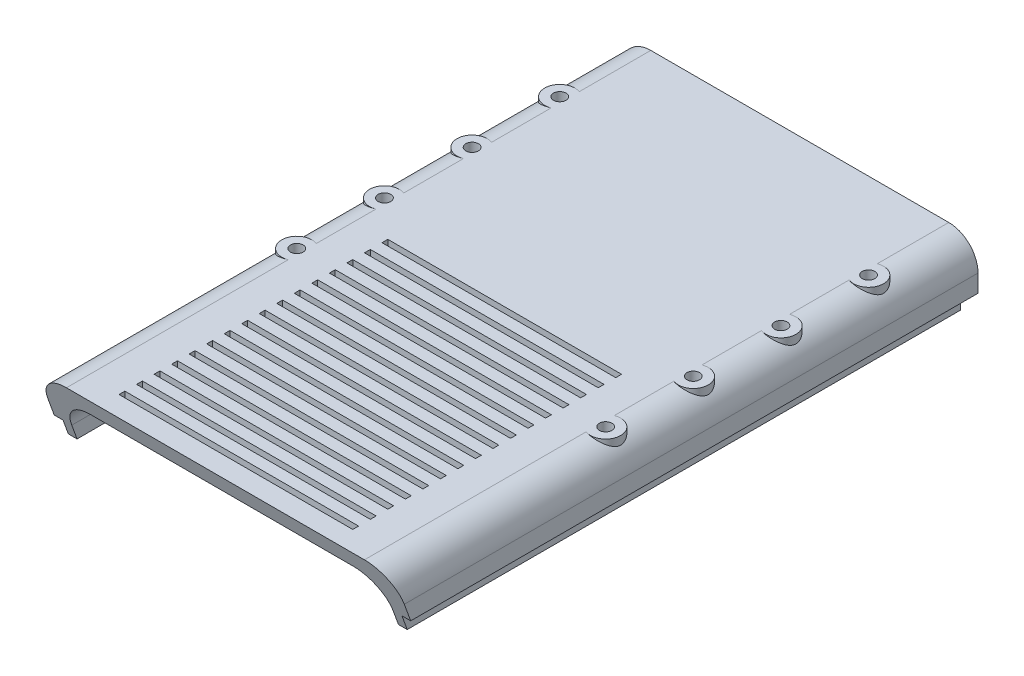
from build123d import *

# Parameters (mm, degrees)
SALIENTE_EXTRUIR1_DEPTH = 3
SALIENTE_EXTRUIR2_DEPTH = 200
CORTAR_EXTRUIR3_DEPTH   = 123
CORTAR_EXTRUIR5_REACH   = 23
CROQUIS6_W              = 80
CROQUIS6_H              = 2
CROQUIS7_W              = 3
CROQUIS7_H              = 3
CORTAR_EXTRUIR6_DEPTH   = 5
CROQUIS8_R              = 5.15
CROQUIS8_R_2            = 2.15
CROQUIS8_R_3            = 5.092623087
CROQUIS8_R_4            = 2.158198504
CROQUIS8_R_5            = 2.156580462
SALIENTE_EXTRUIR3_DEPTH = 21
CORTAR_EXTRUIR7_REACH   = 23
CROQUIS8_2_R            = 2.15
CROQUIS8_2_R_2          = 2.158198504
CROQUIS8_2_R_3          = 2.156580462


with BuildPart() as part:
    # Croquis1 → Saliente-Extruir1 (new body)
    with BuildSketch(Plane.XY):
        with BuildLine():
            Line((-45, 46), (45, 46))
            ThreePointArc((45, 46), (52.071067812, 43.071067812), (55, 36))
            Line((55, 36), (-55, 36))
            ThreePointArc((-55, 36), (-52.071067812, 43.071067812), (-45, 46))
        make_face()
    extrude(amount=SALIENTE_EXTRUIR1_DEPTH)

    # Croquis1_3 → Saliente-Extruir2 (add)
    with BuildSketch(Plane.XY):
        with BuildLine():
            Line((51, 52), (-51, 52))
            ThreePointArc((-51, 52), (-58.071067812, 49.071067812), (-61, 42))
            Line((-61, 42), (-61, 36))
            Line((-61, 36), (-58, 36))
            Line((-58, 36), (-58, 31))
            Line((-58, 31), (-55, 31))
            Line((-55, 31), (-55, 36))
            ThreePointArc((-55, 36), (-52.071067812, 43.071067812), (-45, 46))
            Line((-45, 46), (45, 46))
            ThreePointArc((45, 46), (52.071067812, 43.071067812), (55, 36))
            Line((55, 36), (55, 31))
            Line((55, 31), (58, 31))
            Line((58, 31), (58, 36))
            Line((58, 36), (61, 36))
            Line((61, 36), (61, 42))
            ThreePointArc((61, 42), (58.071067812, 49.071067812), (51, 52))
        make_face()
    extrude(amount=SALIENTE_EXTRUIR2_DEPTH)

    # Croquis4 → Cortar-Extruir3 (cut, through all)
    with BuildSketch(Plane(origin=(61, 0, 0), x_dir=(0, 0, -1), z_dir=(1, 0, 0))):
        Polygon((-200, 52), (-200, 31), (-192.35662508, 31), align=None)
    extrude(amount=-CORTAR_EXTRUIR3_DEPTH, mode=Mode.SUBTRACT)

    # Croquis6 → Cortar-Extruir5 (cut, up to next)
    with BuildSketch(Plane(origin=(0, 52, 0), x_dir=(1, 0, 0), z_dir=(0, 1, 0)), mode=Mode.PRIVATE) as cortar_extruir5_sk1:
        with Locations((0, -192)):
            Rectangle(CROQUIS6_W, CROQUIS6_H)
    cortar_extruir5_tool1 = extrude(cortar_extruir5_sk1.sketch, amount=-CORTAR_EXTRUIR5_REACH, mode=Mode.PRIVATE) & part.part
    add(cortar_extruir5_tool1.solids().sort_by_distance((0, 52, 192))[0], mode=Mode.SUBTRACT)
    # Croquis6 → Cortar-Extruir5 (cut, up to next)
    with BuildSketch(Plane(origin=(0, 52, 0), x_dir=(1, 0, 0), z_dir=(0, 1, 0)), mode=Mode.PRIVATE) as cortar_extruir5_sk2:
        with Locations((0, -186)):
            Rectangle(CROQUIS6_W, CROQUIS6_H)
    cortar_extruir5_tool2 = extrude(cortar_extruir5_sk2.sketch, amount=-CORTAR_EXTRUIR5_REACH, mode=Mode.PRIVATE) & part.part
    add(cortar_extruir5_tool2.solids().sort_by_distance((0, 52, 186))[0], mode=Mode.SUBTRACT)
    # Croquis6 → Cortar-Extruir5 (cut, up to next)
    with BuildSketch(Plane(origin=(0, 52, 0), x_dir=(1, 0, 0), z_dir=(0, 1, 0)), mode=Mode.PRIVATE) as cortar_extruir5_sk3:
        with Locations((0, -180)):
            Rectangle(CROQUIS6_W, CROQUIS6_H)
    cortar_extruir5_tool3 = extrude(cortar_extruir5_sk3.sketch, amount=-CORTAR_EXTRUIR5_REACH, mode=Mode.PRIVATE) & part.part
    add(cortar_extruir5_tool3.solids().sort_by_distance((0, 52, 180))[0], mode=Mode.SUBTRACT)
    # Croquis6 → Cortar-Extruir5 (cut, up to next)
    with BuildSketch(Plane(origin=(0, 52, 0), x_dir=(1, 0, 0), z_dir=(0, 1, 0)), mode=Mode.PRIVATE) as cortar_extruir5_sk4:
        with Locations((0, -174)):
            Rectangle(CROQUIS6_W, CROQUIS6_H)
    cortar_extruir5_tool4 = extrude(cortar_extruir5_sk4.sketch, amount=-CORTAR_EXTRUIR5_REACH, mode=Mode.PRIVATE) & part.part
    add(cortar_extruir5_tool4.solids().sort_by_distance((0, 52, 174))[0], mode=Mode.SUBTRACT)
    # Croquis6 → Cortar-Extruir5 (cut, up to next)
    with BuildSketch(Plane(origin=(0, 52, 0), x_dir=(1, 0, 0), z_dir=(0, 1, 0)), mode=Mode.PRIVATE) as cortar_extruir5_sk5:
        with Locations((0, -168)):
            Rectangle(CROQUIS6_W, CROQUIS6_H)
    cortar_extruir5_tool5 = extrude(cortar_extruir5_sk5.sketch, amount=-CORTAR_EXTRUIR5_REACH, mode=Mode.PRIVATE) & part.part
    add(cortar_extruir5_tool5.solids().sort_by_distance((0, 52, 168))[0], mode=Mode.SUBTRACT)
    # Croquis6 → Cortar-Extruir5 (cut, up to next)
    with BuildSketch(Plane(origin=(0, 52, 0), x_dir=(1, 0, 0), z_dir=(0, 1, 0)), mode=Mode.PRIVATE) as cortar_extruir5_sk6:
        with Locations((0, -162)):
            Rectangle(CROQUIS6_W, CROQUIS6_H)
    cortar_extruir5_tool6 = extrude(cortar_extruir5_sk6.sketch, amount=-CORTAR_EXTRUIR5_REACH, mode=Mode.PRIVATE) & part.part
    add(cortar_extruir5_tool6.solids().sort_by_distance((0, 52, 162))[0], mode=Mode.SUBTRACT)
    # Croquis6 → Cortar-Extruir5 (cut, up to next)
    with BuildSketch(Plane(origin=(0, 52, 0), x_dir=(1, 0, 0), z_dir=(0, 1, 0)), mode=Mode.PRIVATE) as cortar_extruir5_sk7:
        with Locations((0, -156)):
            Rectangle(CROQUIS6_W, CROQUIS6_H)
    cortar_extruir5_tool7 = extrude(cortar_extruir5_sk7.sketch, amount=-CORTAR_EXTRUIR5_REACH, mode=Mode.PRIVATE) & part.part
    add(cortar_extruir5_tool7.solids().sort_by_distance((0, 52, 156))[0], mode=Mode.SUBTRACT)
    # Croquis6 → Cortar-Extruir5 (cut, up to next)
    with BuildSketch(Plane(origin=(0, 52, 0), x_dir=(1, 0, 0), z_dir=(0, 1, 0)), mode=Mode.PRIVATE) as cortar_extruir5_sk8:
        with Locations((0, -150)):
            Rectangle(CROQUIS6_W, CROQUIS6_H)
    cortar_extruir5_tool8 = extrude(cortar_extruir5_sk8.sketch, amount=-CORTAR_EXTRUIR5_REACH, mode=Mode.PRIVATE) & part.part
    add(cortar_extruir5_tool8.solids().sort_by_distance((0, 52, 150))[0], mode=Mode.SUBTRACT)
    # Croquis6 → Cortar-Extruir5 (cut, up to next)
    with BuildSketch(Plane(origin=(0, 52, 0), x_dir=(1, 0, 0), z_dir=(0, 1, 0)), mode=Mode.PRIVATE) as cortar_extruir5_sk9:
        with Locations((0, -144)):
            Rectangle(CROQUIS6_W, CROQUIS6_H)
    cortar_extruir5_tool9 = extrude(cortar_extruir5_sk9.sketch, amount=-CORTAR_EXTRUIR5_REACH, mode=Mode.PRIVATE) & part.part
    add(cortar_extruir5_tool9.solids().sort_by_distance((0, 52, 144))[0], mode=Mode.SUBTRACT)
    # Croquis6 → Cortar-Extruir5 (cut, up to next)
    with BuildSketch(Plane(origin=(0, 52, 0), x_dir=(1, 0, 0), z_dir=(0, 1, 0)), mode=Mode.PRIVATE) as cortar_extruir5_sk10:
        with Locations((0, -138)):
            Rectangle(CROQUIS6_W, CROQUIS6_H)
    cortar_extruir5_tool10 = extrude(cortar_extruir5_sk10.sketch, amount=-CORTAR_EXTRUIR5_REACH, mode=Mode.PRIVATE) & part.part
    add(cortar_extruir5_tool10.solids().sort_by_distance((0, 52, 138))[0], mode=Mode.SUBTRACT)
    # Croquis6 → Cortar-Extruir5 (cut, up to next)
    with BuildSketch(Plane(origin=(0, 52, 0), x_dir=(1, 0, 0), z_dir=(0, 1, 0)), mode=Mode.PRIVATE) as cortar_extruir5_sk11:
        with Locations((0, -132)):
            Rectangle(CROQUIS6_W, CROQUIS6_H)
    cortar_extruir5_tool11 = extrude(cortar_extruir5_sk11.sketch, amount=-CORTAR_EXTRUIR5_REACH, mode=Mode.PRIVATE) & part.part
    add(cortar_extruir5_tool11.solids().sort_by_distance((0, 52, 132))[0], mode=Mode.SUBTRACT)
    # Croquis6 → Cortar-Extruir5 (cut, up to next)
    with BuildSketch(Plane(origin=(0, 52, 0), x_dir=(1, 0, 0), z_dir=(0, 1, 0)), mode=Mode.PRIVATE) as cortar_extruir5_sk12:
        with Locations((0, -126)):
            Rectangle(CROQUIS6_W, CROQUIS6_H)
    cortar_extruir5_tool12 = extrude(cortar_extruir5_sk12.sketch, amount=-CORTAR_EXTRUIR5_REACH, mode=Mode.PRIVATE) & part.part
    add(cortar_extruir5_tool12.solids().sort_by_distance((0, 52, 126))[0], mode=Mode.SUBTRACT)
    # Croquis6 → Cortar-Extruir5 (cut, up to next)
    with BuildSketch(Plane(origin=(0, 52, 0), x_dir=(1, 0, 0), z_dir=(0, 1, 0)), mode=Mode.PRIVATE) as cortar_extruir5_sk13:
        with Locations((0, -120)):
            Rectangle(CROQUIS6_W, CROQUIS6_H)
    cortar_extruir5_tool13 = extrude(cortar_extruir5_sk13.sketch, amount=-CORTAR_EXTRUIR5_REACH, mode=Mode.PRIVATE) & part.part
    add(cortar_extruir5_tool13.solids().sort_by_distance((0, 52, 120))[0], mode=Mode.SUBTRACT)
    # Croquis6 → Cortar-Extruir5 (cut, up to next)
    with BuildSketch(Plane(origin=(0, 52, 0), x_dir=(1, 0, 0), z_dir=(0, 1, 0)), mode=Mode.PRIVATE) as cortar_extruir5_sk14:
        with Locations((0, -114)):
            Rectangle(CROQUIS6_W, CROQUIS6_H)
    cortar_extruir5_tool14 = extrude(cortar_extruir5_sk14.sketch, amount=-CORTAR_EXTRUIR5_REACH, mode=Mode.PRIVATE) & part.part
    add(cortar_extruir5_tool14.solids().sort_by_distance((0, 52, 114))[0], mode=Mode.SUBTRACT)
    # Croquis6 → Cortar-Extruir5 (cut, up to next)
    with BuildSketch(Plane(origin=(0, 52, 0), x_dir=(1, 0, 0), z_dir=(0, 1, 0)), mode=Mode.PRIVATE) as cortar_extruir5_sk15:
        with Locations((0, -108)):
            Rectangle(CROQUIS6_W, CROQUIS6_H)
    cortar_extruir5_tool15 = extrude(cortar_extruir5_sk15.sketch, amount=-CORTAR_EXTRUIR5_REACH, mode=Mode.PRIVATE) & part.part
    add(cortar_extruir5_tool15.solids().sort_by_distance((0, 52, 108))[0], mode=Mode.SUBTRACT)
    # Croquis6 → Cortar-Extruir5 (cut, up to next)
    with BuildSketch(Plane(origin=(0, 52, 0), x_dir=(1, 0, 0), z_dir=(0, 1, 0)), mode=Mode.PRIVATE) as cortar_extruir5_sk16:
        with Locations((0, -102)):
            Rectangle(CROQUIS6_W, CROQUIS6_H)
    cortar_extruir5_tool16 = extrude(cortar_extruir5_sk16.sketch, amount=-CORTAR_EXTRUIR5_REACH, mode=Mode.PRIVATE) & part.part
    add(cortar_extruir5_tool16.solids().sort_by_distance((0, 52, 102))[0], mode=Mode.SUBTRACT)

    # Croquis7 → Cortar-Extruir6 (cut)
    with BuildSketch(Plane.XZ.offset(-36)):
        with Locations((-56.5, 1.5)):
            Rectangle(CROQUIS7_W, CROQUIS7_H)
        with Locations((56.5, 1.5)):
            Rectangle(CROQUIS7_W, CROQUIS7_H)
    extrude(amount=CORTAR_EXTRUIR6_DEPTH, mode=Mode.SUBTRACT)

    # Croquis8 → Saliente-Extruir3 (add)
    with BuildSketch(Plane(origin=(0, 52, 0), x_dir=(1, 0, 0), z_dir=(0, 1, 0))):
        with Locations((-52.85, -119.3)):
            Circle(CROQUIS8_R)
        with Locations((-52.85, -119.3)):
            Circle(CROQUIS8_R_2, mode=Mode.SUBTRACT)
        with Locations((-52.85, -89.3)):
            Circle(CROQUIS8_R_3)
        with Locations((-52.85, -89.3)):
            Circle(CROQUIS8_R_2, mode=Mode.SUBTRACT)
        with Locations((-52.85, -59.3)):
            Circle(CROQUIS8_R)
        with Locations((-52.85, -59.3)):
            Circle(CROQUIS8_R_4, mode=Mode.SUBTRACT)
        with Locations((-52.85, -29.3)):
            Circle(CROQUIS8_R)
        with Locations((-52.85, -29.3)):
            Circle(CROQUIS8_R_2, mode=Mode.SUBTRACT)
        with Locations((52.85, -119.3)):
            Circle(CROQUIS8_R)
        with Locations((52.85, -119.3)):
            Circle(CROQUIS8_R_2, mode=Mode.SUBTRACT)
        with Locations((52.85, -89.3)):
            Circle(CROQUIS8_R)
        with Locations((52.85, -89.3)):
            Circle(CROQUIS8_R_2, mode=Mode.SUBTRACT)
        with Locations((52.85, -59.3)):
            Circle(CROQUIS8_R)
        with Locations((52.85, -59.3)):
            Circle(CROQUIS8_R_5, mode=Mode.SUBTRACT)
        with Locations((52.85, -29.3)):
            Circle(CROQUIS8_R)
        with Locations((52.85, -29.3)):
            Circle(CROQUIS8_R_2, mode=Mode.SUBTRACT)
    extrude(amount=-SALIENTE_EXTRUIR3_DEPTH)

    # Croquis8_2 → Cortar-Extruir7 (cut, up to next)
    with BuildSketch(Plane(origin=(0, 52, 0), x_dir=(1, 0, 0), z_dir=(0, 1, 0)), mode=Mode.PRIVATE) as cortar_extruir7_sk1:
        with Locations((-52.85, -29.3)):
            Circle(CROQUIS8_2_R)
    cortar_extruir7_tool1 = extrude(cortar_extruir7_sk1.sketch, amount=-CORTAR_EXTRUIR7_REACH, mode=Mode.PRIVATE) & part.part
    add(cortar_extruir7_tool1.solids().sort_by_distance((-52.85, 52, 29.3))[0], mode=Mode.SUBTRACT)
    # Croquis8_2 → Cortar-Extruir7 (cut, up to next)
    with BuildSketch(Plane(origin=(0, 52, 0), x_dir=(1, 0, 0), z_dir=(0, 1, 0)), mode=Mode.PRIVATE) as cortar_extruir7_sk2:
        with Locations((-52.85, -59.3)):
            Circle(CROQUIS8_2_R_2)
    cortar_extruir7_tool2 = extrude(cortar_extruir7_sk2.sketch, amount=-CORTAR_EXTRUIR7_REACH, mode=Mode.PRIVATE) & part.part
    add(cortar_extruir7_tool2.solids().sort_by_distance((-52.85, 52, 59.3))[0], mode=Mode.SUBTRACT)
    # Croquis8_2 → Cortar-Extruir7 (cut, up to next)
    with BuildSketch(Plane(origin=(0, 52, 0), x_dir=(1, 0, 0), z_dir=(0, 1, 0)), mode=Mode.PRIVATE) as cortar_extruir7_sk3:
        with Locations((-52.85, -89.3)):
            Circle(CROQUIS8_2_R)
    cortar_extruir7_tool3 = extrude(cortar_extruir7_sk3.sketch, amount=-CORTAR_EXTRUIR7_REACH, mode=Mode.PRIVATE) & part.part
    add(cortar_extruir7_tool3.solids().sort_by_distance((-52.85, 52, 89.3))[0], mode=Mode.SUBTRACT)
    # Croquis8_2 → Cortar-Extruir7 (cut, up to next)
    with BuildSketch(Plane(origin=(0, 52, 0), x_dir=(1, 0, 0), z_dir=(0, 1, 0)), mode=Mode.PRIVATE) as cortar_extruir7_sk4:
        with Locations((-52.85, -119.3)):
            Circle(CROQUIS8_2_R)
    cortar_extruir7_tool4 = extrude(cortar_extruir7_sk4.sketch, amount=-CORTAR_EXTRUIR7_REACH, mode=Mode.PRIVATE) & part.part
    add(cortar_extruir7_tool4.solids().sort_by_distance((-52.85, 52, 119.3))[0], mode=Mode.SUBTRACT)
    # Croquis8_2 → Cortar-Extruir7 (cut, up to next)
    with BuildSketch(Plane(origin=(0, 52, 0), x_dir=(1, 0, 0), z_dir=(0, 1, 0)), mode=Mode.PRIVATE) as cortar_extruir7_sk5:
        with Locations((52.85, -119.3)):
            Circle(CROQUIS8_2_R)
    cortar_extruir7_tool5 = extrude(cortar_extruir7_sk5.sketch, amount=-CORTAR_EXTRUIR7_REACH, mode=Mode.PRIVATE) & part.part
    add(cortar_extruir7_tool5.solids().sort_by_distance((52.85, 52, 119.3))[0], mode=Mode.SUBTRACT)
    # Croquis8_2 → Cortar-Extruir7 (cut, up to next)
    with BuildSketch(Plane(origin=(0, 52, 0), x_dir=(1, 0, 0), z_dir=(0, 1, 0)), mode=Mode.PRIVATE) as cortar_extruir7_sk6:
        with Locations((52.85, -89.3)):
            Circle(CROQUIS8_2_R)
    cortar_extruir7_tool6 = extrude(cortar_extruir7_sk6.sketch, amount=-CORTAR_EXTRUIR7_REACH, mode=Mode.PRIVATE) & part.part
    add(cortar_extruir7_tool6.solids().sort_by_distance((52.85, 52, 89.3))[0], mode=Mode.SUBTRACT)
    # Croquis8_2 → Cortar-Extruir7 (cut, up to next)
    with BuildSketch(Plane(origin=(0, 52, 0), x_dir=(1, 0, 0), z_dir=(0, 1, 0)), mode=Mode.PRIVATE) as cortar_extruir7_sk7:
        with Locations((52.85, -59.3)):
            Circle(CROQUIS8_2_R_3)
    cortar_extruir7_tool7 = extrude(cortar_extruir7_sk7.sketch, amount=-CORTAR_EXTRUIR7_REACH, mode=Mode.PRIVATE) & part.part
    add(cortar_extruir7_tool7.solids().sort_by_distance((52.85, 52, 59.3))[0], mode=Mode.SUBTRACT)
    # Croquis8_2 → Cortar-Extruir7 (cut, up to next)
    with BuildSketch(Plane(origin=(0, 52, 0), x_dir=(1, 0, 0), z_dir=(0, 1, 0)), mode=Mode.PRIVATE) as cortar_extruir7_sk8:
        with Locations((52.85, -29.3)):
            Circle(CROQUIS8_2_R)
    cortar_extruir7_tool8 = extrude(cortar_extruir7_sk8.sketch, amount=-CORTAR_EXTRUIR7_REACH, mode=Mode.PRIVATE) & part.part
    add(cortar_extruir7_tool8.solids().sort_by_distance((52.85, 52, 29.3))[0], mode=Mode.SUBTRACT)


solid = part.part
